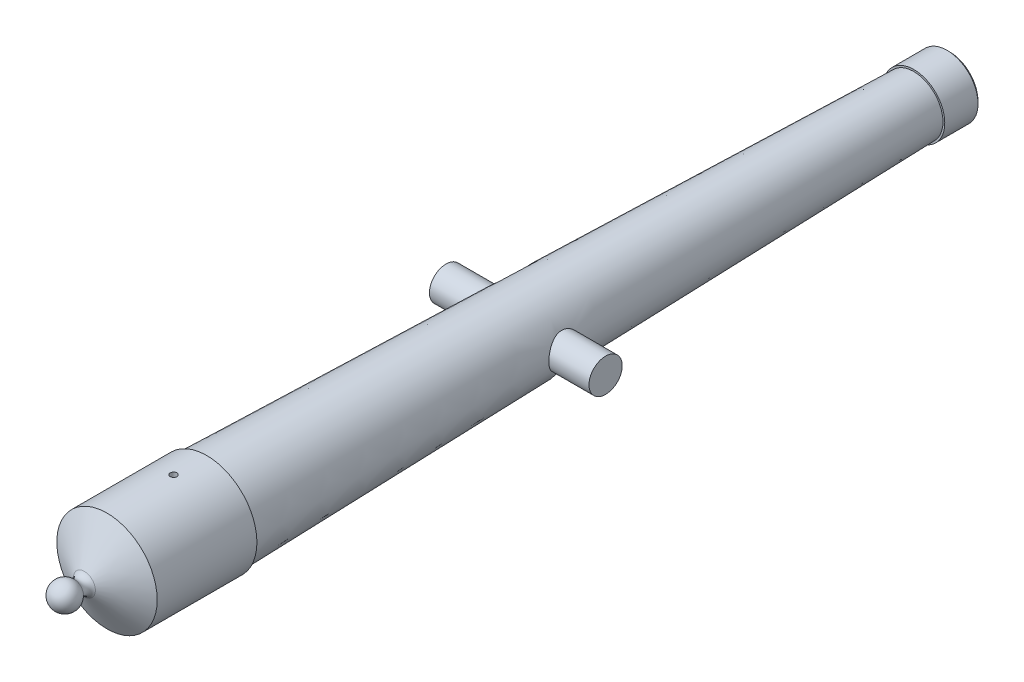
from build123d import *

# Parameters (mm, degrees)
BOSS_EXTRUDE1_START = 10.16
SKETCH3_R           = 3.175
BOSS_EXTRUDE1_DEPTH = 5.08
SKETCH4_R           = 0.635
CUT_EXTRUDE1_DEPTH  = 10.588339362


with BuildPart() as part:
    # Sketch1 → Revolve1 (revolve)
    with BuildSketch(Plane(origin=(0, 0, 0), x_dir=(0, 0, -1), z_dir=(1, 0, 0))):
        with BuildLine():
            Line((-76.2, 2.8321), (76.2, 2.8321))
            Line((76.2, 2.8321), (81.001685274, 3.678766667))
            Line((81.001685274, 3.678766667), (81.001685274, 5.3721))
            Line((81.001685274, 5.3721), (80.493685274, 5.385402448))
            Line((80.493685274, 5.385402448), (80.493685274, 5.893402448))
            Line((80.493685274, 5.893402448), (74.143685274, 5.893402448))
            Line((74.143685274, 5.893402448), (74.143685274, 5.55168305))
            Line((74.143685274, 5.55168305), (-60.96, 9.089497556))
            Line((-60.96, 9.089497556), (-60.96, 9.588339362))
            Line((-60.96, 9.588339362), (-80.01, 9.588339362))
            Line((-80.01, 9.588339362), (-84.333416613, 2.099962126))
            ThreePointArc((-84.333416613, 2.099962126), (-85.257877242, 1.477131543), (-86.317456021, 1.823308084))
            ThreePointArc((-86.317456021, 1.823308084), (-89.075761951, 2.339152699), (-90.625830312, 0))
            Line((-90.625830312, 0), (-85.545830312, 0))
            Line((-85.545830312, 0), (-76.2, 0))
            Line((-76.2, 0), (-76.2, 2.8321))
        make_face()
    revolve(axis=Axis((0, 0, 101.6), (0, 0, -1)))

    # Sketch3 → Boss-Extrude1 (add, symmetric)
    with BuildSketch(Plane(origin=(0, 0, 0), x_dir=(0, 0, -1), z_dir=(1, 0, 0)).offset(BOSS_EXTRUDE1_START)):
        Circle(SKETCH3_R)
    boss_extrude1 = extrude(amount=BOSS_EXTRUDE1_DEPTH, both=True)

    # Mirror1: Boss-Extrude1 across plane
    add(boss_extrude1.mirror(Plane(origin=(0, 0, 0), x_dir=(0, 0, 1), z_dir=(1, 0, 0))))

    # Sketch4 → Cut-Extrude1 (cut, through all)
    with BuildSketch(Plane(origin=(0, 0, 0), x_dir=(1, 0, 0), z_dir=(0, 1, 0))):
        with Locations((0, -67.31)):
            Circle(SKETCH4_R)
    extrude(amount=CUT_EXTRUDE1_DEPTH, mode=Mode.SUBTRACT)


solid = part.part
